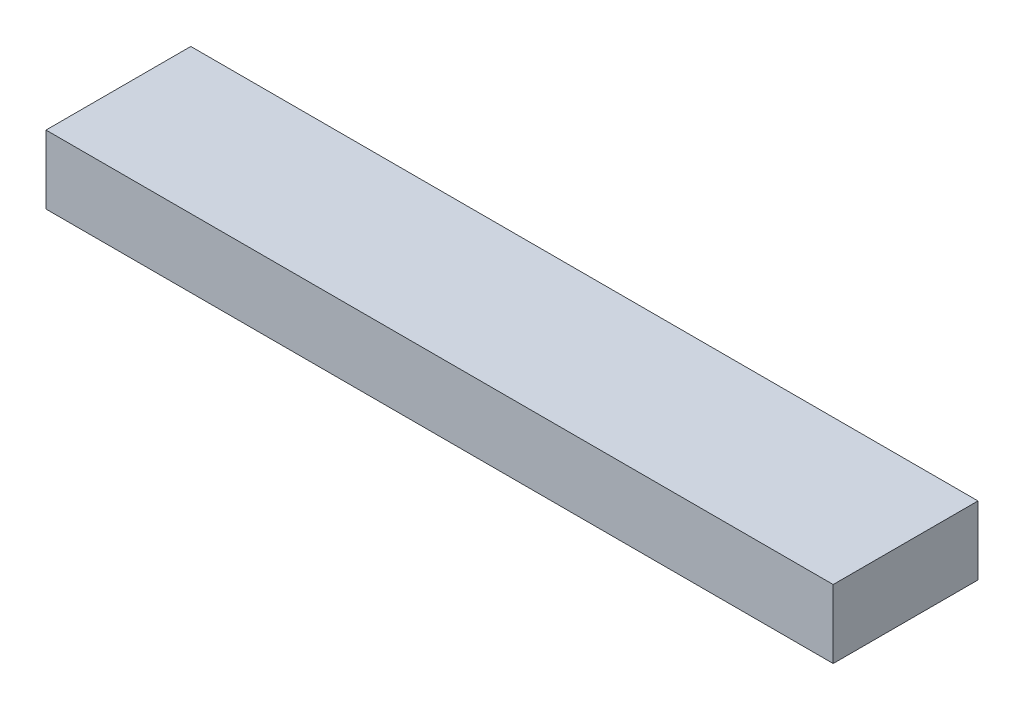
from build123d import *

# Parameters (mm, degrees)
SKETCH1_W           = 299
SKETCH1_H           = 26
BOSS_EXTRUDE1_DEPTH = 55


with BuildPart() as part:
    # Sketch1 → Boss-Extrude1 (new body)
    with BuildSketch(Plane.XY):
        Rectangle(SKETCH1_W, SKETCH1_H)
    extrude(amount=BOSS_EXTRUDE1_DEPTH)


solid = part.part
